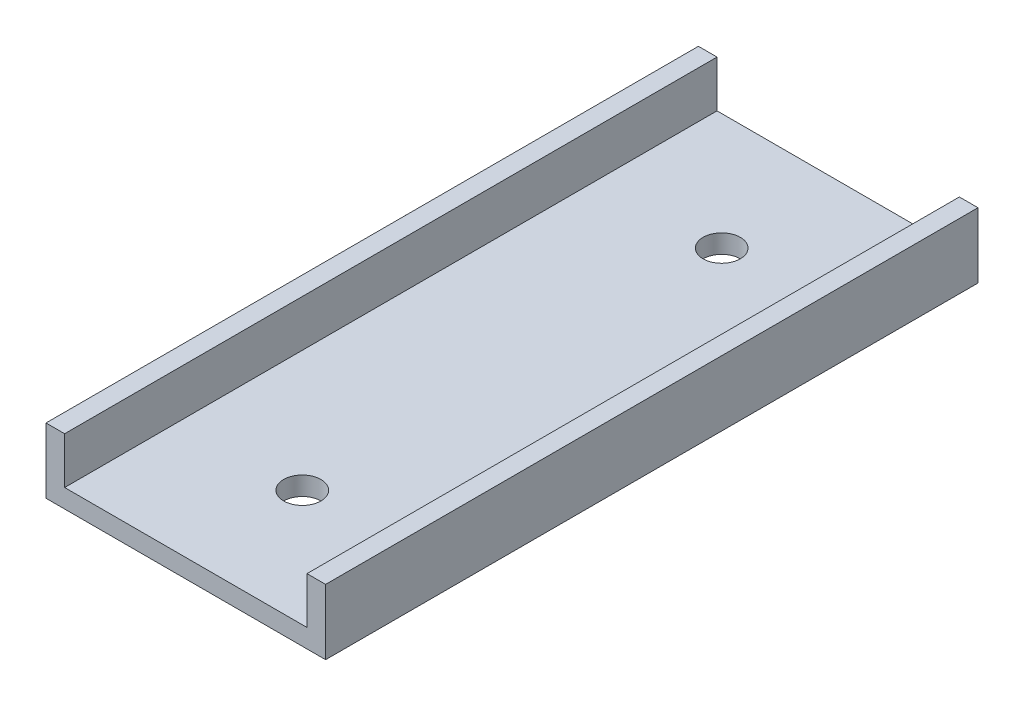
from build123d import *

# Parameters (mm, degrees)
EXTRUDE_1_DEPTH     = 70
SKETCH_2_R          = 2
CUT_EXTRUDE_1_DEPTH = 70


with BuildPart() as part:
    # 草图1 → 凸台-拉伸1 (new body)
    with BuildSketch(Plane.XY):
        Polygon((-39.739058503, 13.578549771), (-39.739058503, 6.578549771), (-9.739058503, 6.578549771), (-9.739058503, 13.578549771), (-11.739058503, 13.578549771), (-11.739058503, 8.578549771), (-37.739058503, 8.578549771), (-37.739058503, 13.578549771), align=None)
    extrude(amount=EXTRUDE_1_DEPTH)

    # 草图2 → 切除-拉伸1 (cut)
    with BuildSketch(Plane(origin=(0, 6.578549771, 0), x_dir=(-1, 0, 0), z_dir=(0, -1, 0))):
        with Locations((24.739058503, -12.5)):
            Circle(SKETCH_2_R)
        with Locations((24.739058503, -57.5)):
            Circle(SKETCH_2_R)
    extrude(amount=-CUT_EXTRUDE_1_DEPTH, mode=Mode.SUBTRACT)


solid = part.part
